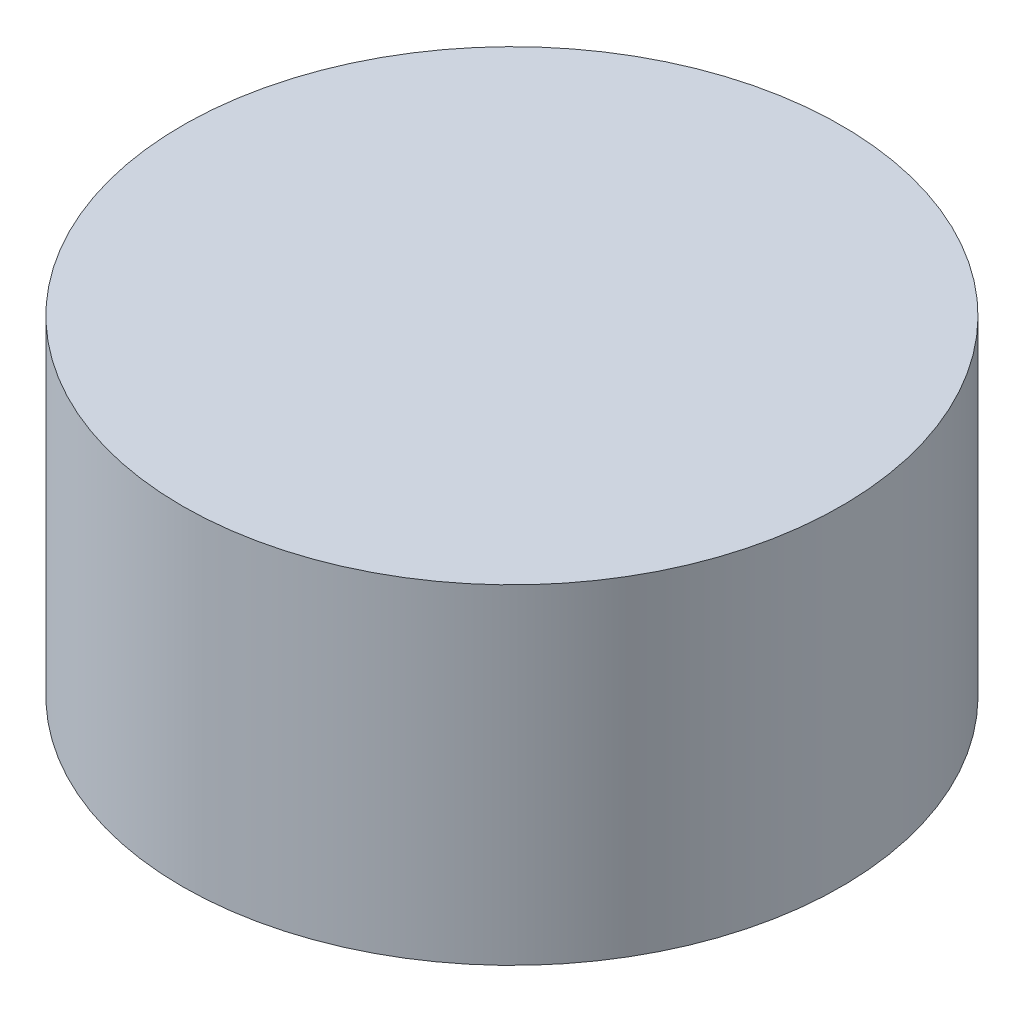
from build123d import *

# Parameters (mm, degrees)
SKETCH1_R           = 1
BOSS_EXTRUDE1_DEPTH = 1


with BuildPart() as part:
    # Sketch1 → Boss-Extrude1 (new body)
    with BuildSketch(Plane(origin=(0, 0, 0), x_dir=(1, 0, 0), z_dir=(0, 1, 0))):
        Circle(SKETCH1_R)
    extrude(amount=BOSS_EXTRUDE1_DEPTH)


solid = part.part
